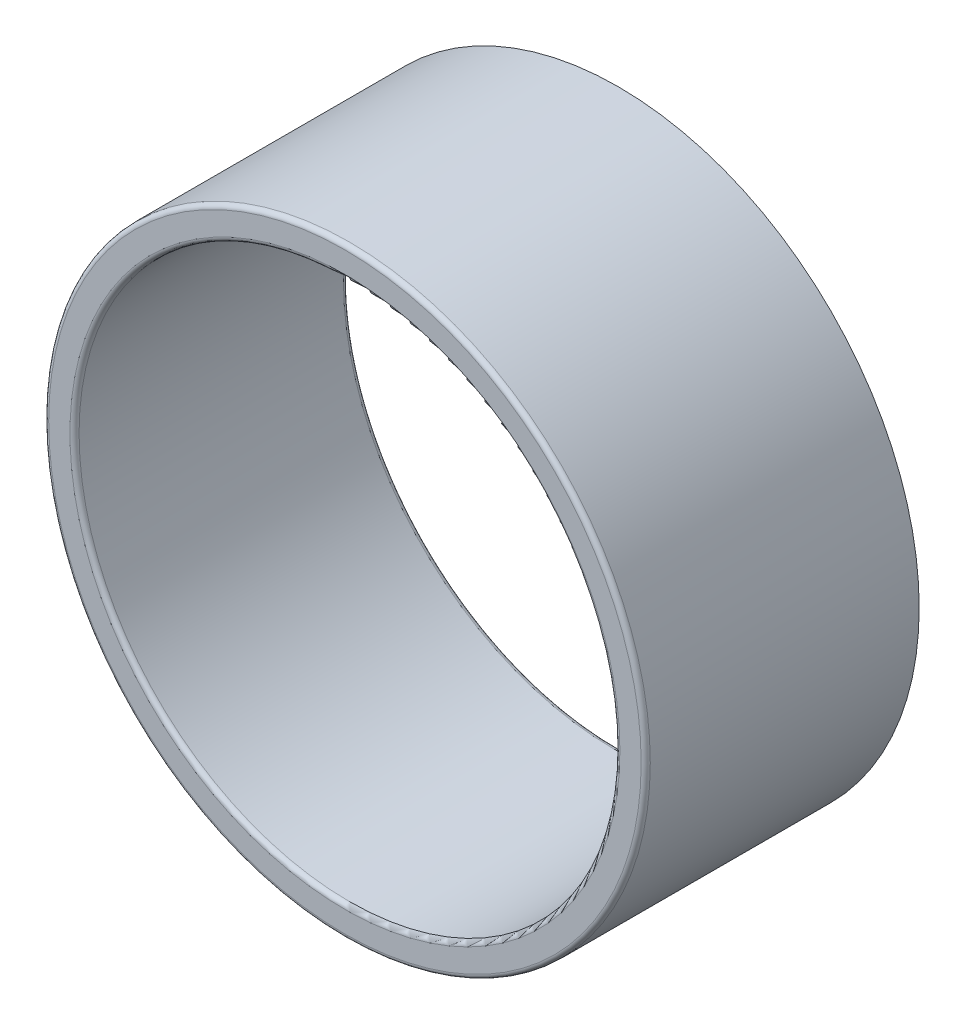
from build123d import *

# Parameters (mm, degrees)
SKETCH1_R           = 99
SKETCH1_R_2         = 89
BOSS_EXTRUDE1_DEPTH = 90
FILLET1_R           = 1.5


with BuildPart() as part:
    # Sketch1 → Boss-Extrude1 (new body)
    with BuildSketch(Plane.XY):
        with Locations((232.735026919, 15)):
            Circle(SKETCH1_R)
        with Locations((232.735026919, 15)):
            Circle(SKETCH1_R_2, mode=Mode.SUBTRACT)
    extrude(amount=-BOSS_EXTRUDE1_DEPTH)

    # Fillet1
    fillet1_edges = [part.edges().sort_by_distance(p)[0] for p in [
        (133.735026919, 15, 0),
        (143.735026919, 15, -90),
        (143.735026919, 15, 0),
    ]]
    fillet(fillet1_edges, radius=FILLET1_R)


solid = part.part
